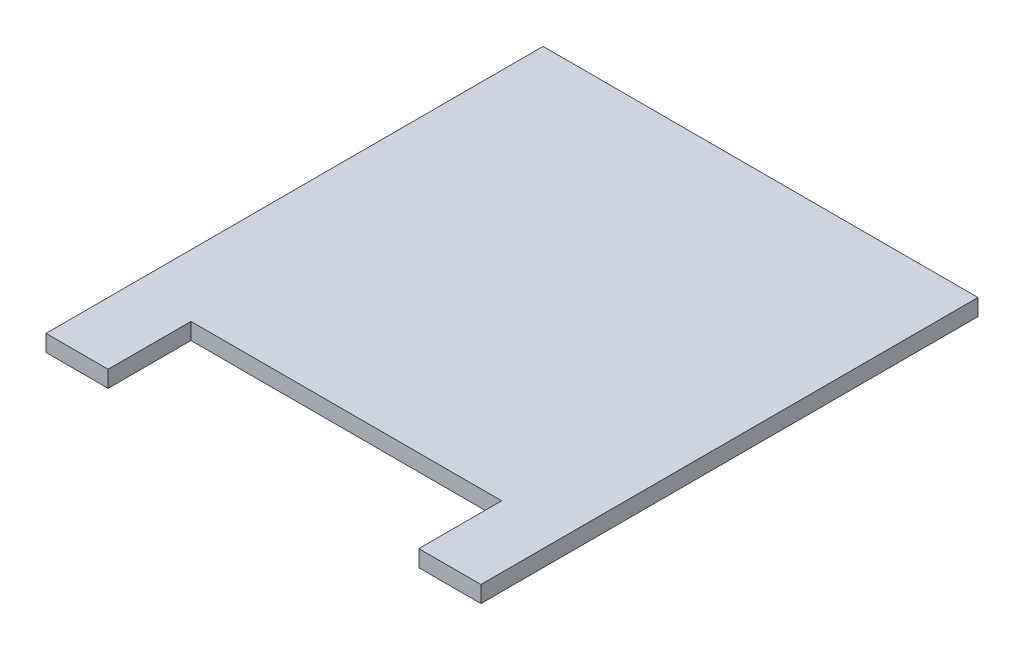
from build123d import *

# Parameters (mm, degrees)
SALIENTE_EXTRUIR1_DEPTH = 16


with BuildPart() as part:
    # Croquis1 → Saliente-Extruir1 (new body)
    with BuildSketch(Plane(origin=(0, 0, 0), x_dir=(1, 0, 0), z_dir=(0, 1, 0))):
        Polygon((150, -240), (210, -240), (210, 240), (-210, 240), (-210, -240), (-150, -240), (-150, -160), (150, -160), align=None)
    extrude(amount=SALIENTE_EXTRUIR1_DEPTH)


solid = part.part
